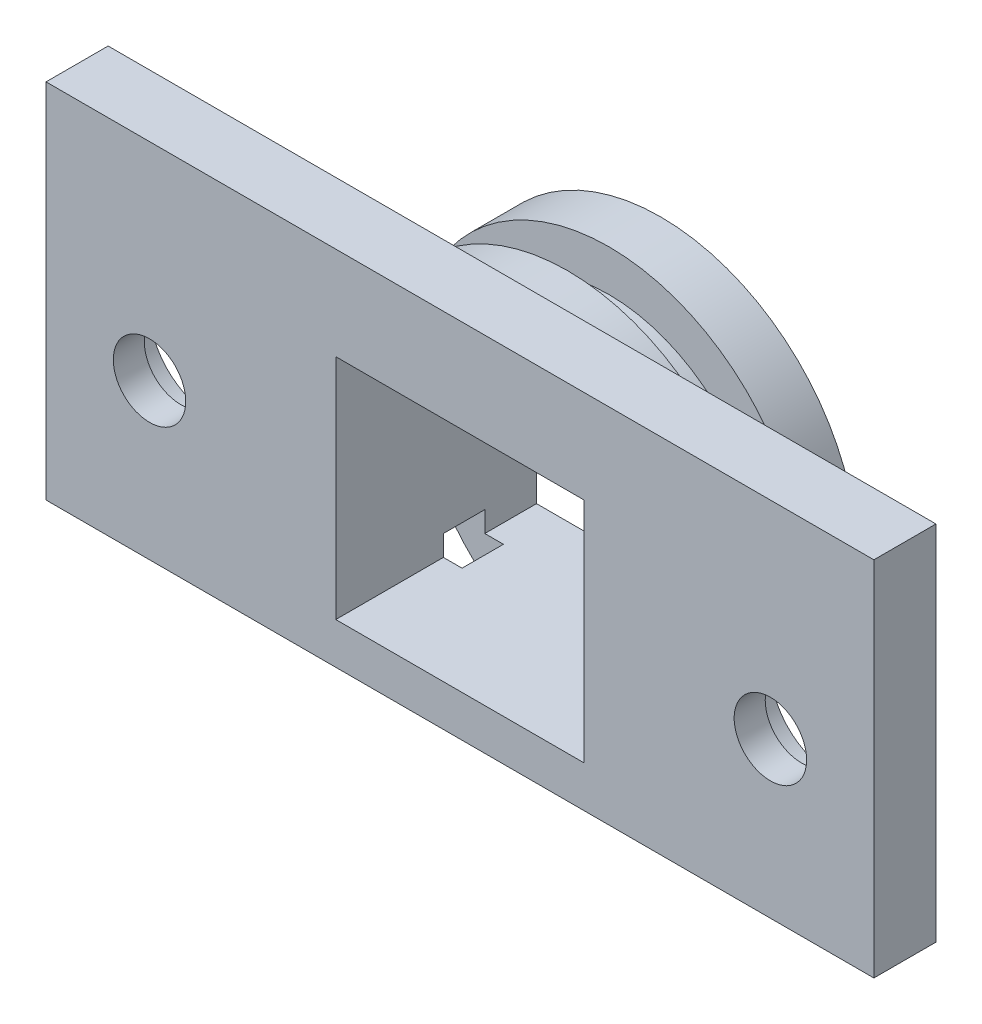
from build123d import *

# Parameters (mm, degrees)
BOSS_EXTRUDE1_DEPTH = 2.2
SKETCH3_R           = 7.5
BOSS_EXTRUDE2_DEPTH = 2
BOSS_EXTRUDE3_DEPTH = 2.5
SKETCH5_W           = 12
SKETCH5_H           = 11
CUT_EXTRUDE1_DEPTH  = 7.7
SKETCH6_W           = 40
SKETCH6_H           = 20
SKETCH6_W_2         = 12
SKETCH6_H_2         = 11
BOSS_EXTRUDE4_DEPTH = 3
SKETCH7_R           = 1.75
CUT_EXTRUDE2_DEPTH  = 10.7
SKETCH8_R           = 3
CUT_EXTRUDE3_DEPTH  = 1.5
SKETCH9_W           = 40
SKETCH9_H           = 2.5
CUT_EXTRUDE4_DEPTH  = 10.7


with BuildPart() as part:
    # Sketch2 → Boss-Extrude1 (new body)
    with BuildSketch(Plane.XY):
        with BuildLine():
            Line((-5.830951895, -7.5), (5.830951895, -7.5))
            ThreePointArc((5.830951895, -7.5), (0, 9.5), (-5.830951895, -7.5))
        make_face()
    extrude(amount=-BOSS_EXTRUDE1_DEPTH)

    # Sketch3 → Boss-Extrude2 (add)
    with BuildSketch(Plane(origin=(0, 0, -2.2), x_dir=(-1, 0, 0), z_dir=(0, 0, -1))):
        Circle(SKETCH3_R)
    extrude(amount=BOSS_EXTRUDE2_DEPTH)

    # Sketch4 → Boss-Extrude3 (add)
    with BuildSketch(Plane(origin=(0, 0, -4.2), x_dir=(-1, 0, 0), z_dir=(0, 0, -1))):
        with BuildLine():
            Line((-5.830951895, -7.5), (5.830951895, -7.5))
            ThreePointArc((5.830951895, -7.5), (0, 9.5), (-5.830951895, -7.5))
        make_face()
    extrude(amount=BOSS_EXTRUDE3_DEPTH)

    # Sketch5 → Cut-Extrude1 (cut, through all)
    with BuildSketch(Plane(origin=(0, 0, -6.7), x_dir=(-1, 0, 0), z_dir=(0, 0, -1))):
        Rectangle(SKETCH5_W, SKETCH5_H)
    extrude(amount=-CUT_EXTRUDE1_DEPTH, mode=Mode.SUBTRACT)

    # Sketch6 → Boss-Extrude4 (add)
    with BuildSketch(Plane.XY):
        Rectangle(SKETCH6_W, SKETCH6_H)
        Rectangle(SKETCH6_W_2, SKETCH6_H_2, mode=Mode.SUBTRACT)
    extrude(amount=BOSS_EXTRUDE4_DEPTH)

    # Sketch7 → Cut-Extrude2 (cut, through all)
    with BuildSketch(Plane.XY.offset(3)):
        with Locations((-15, 0)):
            Circle(SKETCH7_R)
        with Locations((15, 0)):
            Circle(SKETCH7_R)
    extrude(amount=-CUT_EXTRUDE2_DEPTH, mode=Mode.SUBTRACT)

    # Sketch8 → Cut-Extrude3 (cut)
    with BuildSketch(Plane(origin=(0, 0, 0), x_dir=(-1, 0, 0), z_dir=(0, 0, -1))):
        with Locations((15, 0)):
            Circle(SKETCH8_R)
        with Locations((-15, 0)):
            Circle(SKETCH8_R)
    extrude(amount=-CUT_EXTRUDE3_DEPTH, mode=Mode.SUBTRACT)

    # Sketch9 → Cut-Extrude4 (cut, through all)
    with BuildSketch(Plane(origin=(0, 0, -6.7), x_dir=(-1, 0, 0), z_dir=(0, 0, -1))):
        with Locations((0, -8.75)):
            Rectangle(SKETCH9_W, SKETCH9_H)
    extrude(amount=-CUT_EXTRUDE4_DEPTH, mode=Mode.SUBTRACT)


solid = part.part
